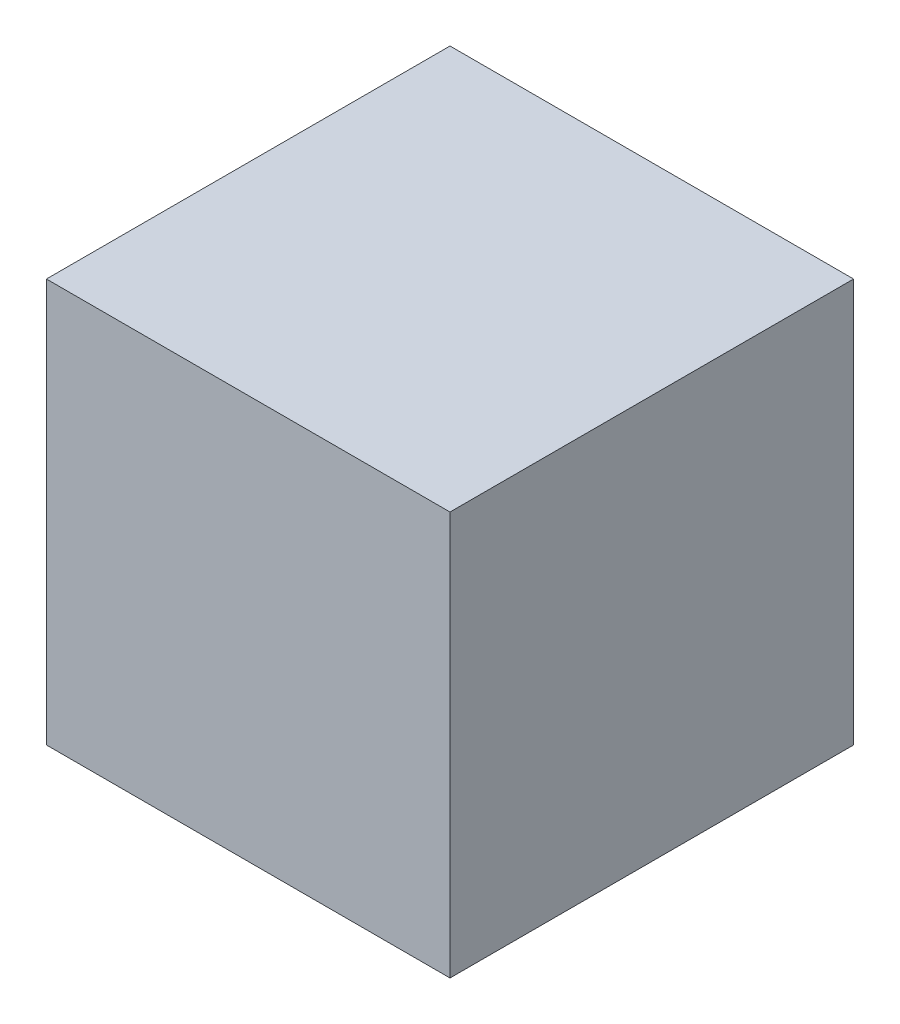
from build123d import *

# Parameters (mm, degrees)
SKETCH2_W           = 1000
SKETCH2_H           = 1000
BOSS_EXTRUDE1_DEPTH = 990
SHELL2_T            = -10
SKETCH3_W           = 1000
SKETCH3_H           = 1000
BOSS_EXTRUDE2_DEPTH = 10


with BuildPart() as part:
    # Sketch2 → Boss-Extrude1 (new body)
    with BuildSketch(Plane(origin=(0, 0, 0), x_dir=(1, 0, 0), z_dir=(0, 1, 0))):
        with Locations((500, 500)):
            Rectangle(SKETCH2_W, SKETCH2_H)
    extrude(amount=BOSS_EXTRUDE1_DEPTH)

    # Shell2
    shell2_openings = [part.faces().sort_by_distance(p)[0] for p in [
        (500, 990, -500),
    ]]
    offset(amount=SHELL2_T, openings=shell2_openings, kind=Kind.INTERSECTION)

    # Sketch3 → Boss-Extrude2 (add)
    with BuildSketch(Plane(origin=(0, 990, 0), x_dir=(1, 0, 0), z_dir=(0, 1, 0))):
        with Locations((500, 500)):
            Rectangle(SKETCH3_W, SKETCH3_H)
    extrude(amount=BOSS_EXTRUDE2_DEPTH)


solid = part.part
